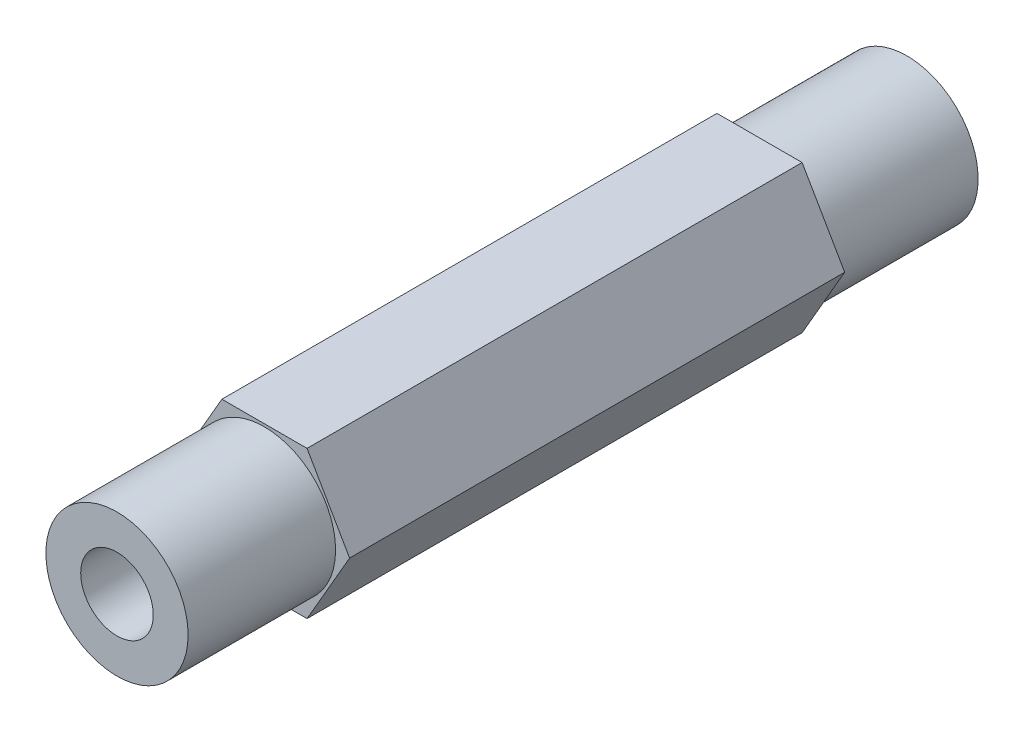
from build123d import *

# Parameters (mm, degrees)
BOSS_EXTRUDE1_DEPTH = 76.2
SKETCH2_R           = 6.86
CUT_EXTRUDE1_DEPTH  = 14.224
SKETCH3_R           = 6.86
CUT_EXTRUDE2_DEPTH  = 14.224
SKETCH4_R           = 3.5
CUT_EXTRUDE3_DEPTH  = 77.2


with BuildPart() as part:
    # Sketch1 → Boss-Extrude1 (new body)
    with BuildSketch(Plane(origin=(0, 0, 0), x_dir=(0, 1, 0), z_dir=(0, 0, 1))):
        Polygon((7.112, -4.106115114), (7.112, 4.106115114), (0, 8.212230229), (-7.112, 4.106115114), (-7.112, -4.106115114), (0, -8.212230229), align=None)
    extrude(amount=BOSS_EXTRUDE1_DEPTH)

    # Sketch2 → Cut-Extrude1 (cut)
    with BuildSketch(Plane.XY.offset(76.2)):
        Polygon((8.212230229, 0), (4.106115114, 7.112), (-4.106115114, 7.112), (-8.212230229, 0), (-4.106115114, -7.112), (4.106115114, -7.112), align=None)
        Circle(SKETCH2_R, mode=Mode.SUBTRACT)
    extrude(amount=-CUT_EXTRUDE1_DEPTH, mode=Mode.SUBTRACT)

    # Sketch3 → Cut-Extrude2 (cut)
    with BuildSketch(Plane(origin=(0, 0, 0), x_dir=(1, 0, 0), z_dir=(0, 0, -1))):
        Polygon((4.106115114, -7.112), (8.212230229, 0), (4.106115114, 7.112), (-4.106115114, 7.112), (-8.212230229, 0), (-4.106115114, -7.112), align=None)
        Circle(SKETCH3_R, mode=Mode.SUBTRACT)
    extrude(amount=-CUT_EXTRUDE2_DEPTH, mode=Mode.SUBTRACT)

    # Sketch4 → Cut-Extrude3 (cut, through all)
    with BuildSketch(Plane(origin=(0, 0, 0), x_dir=(1, 0, 0), z_dir=(0, 0, -1))):
        Circle(SKETCH4_R)
    extrude(amount=-CUT_EXTRUDE3_DEPTH, mode=Mode.SUBTRACT)


solid = part.part
